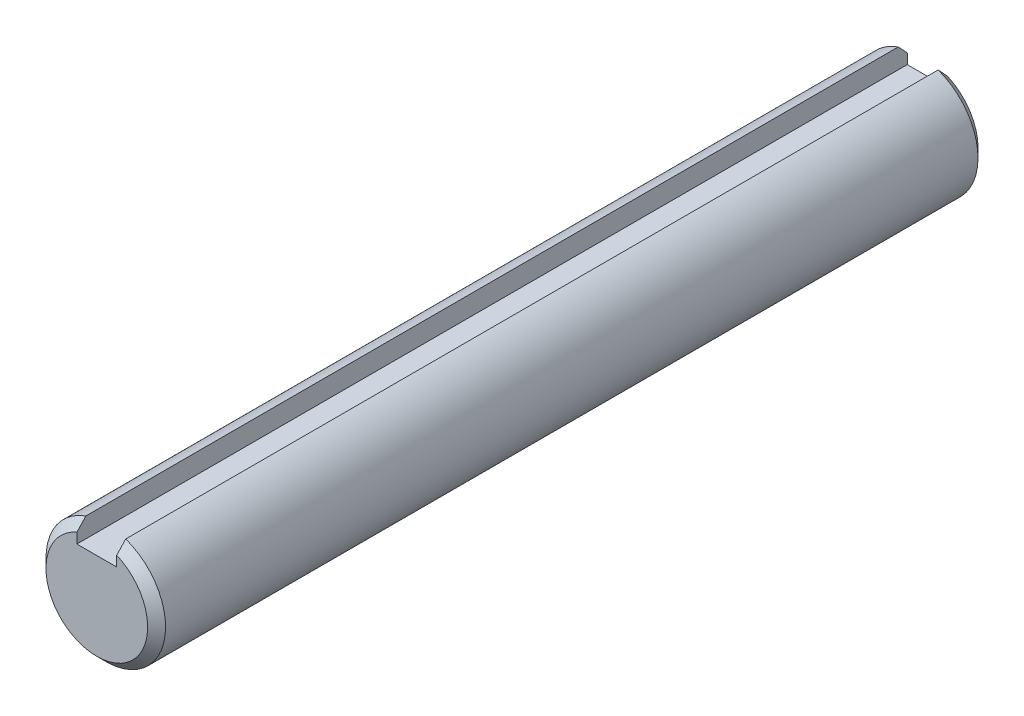
from build123d import *

# Parameters (mm, degrees)
SKETCH1_R           = 9
EXTRUDE1_DEPTH      = 62.5
CHAMFER1_SIZE       = 1.35
SKETCH3_W           = 6
SKETCH3_H           = 3.5
EXTRUDE2_DEPTH      = 63.5
EXTRUDE2_DEPTH_BACK = 63.5


with BuildPart() as part:
    # Sketch1 → Extrude1 (new body, symmetric)
    with BuildSketch(Plane.XY):
        Circle(SKETCH1_R)
    extrude(amount=EXTRUDE1_DEPTH, both=True)

    # Chamfer1
    chamfer1_edges = [part.edges().sort_by_distance(p)[0] for p in [
        (-9, 0, -62.5),
        (-9, 0, 62.5),
    ]]
    chamfer(chamfer1_edges, length=CHAMFER1_SIZE)

    # Sketch3 → Extrude2 (cut, two sides)
    with BuildSketch(Plane.XY) as extrude2_sk:
        with Locations((0, 7.25)):
            Rectangle(SKETCH3_W, SKETCH3_H)
    extrude(amount=EXTRUDE2_DEPTH, mode=Mode.SUBTRACT)
    extrude(extrude2_sk.sketch, amount=-EXTRUDE2_DEPTH_BACK, mode=Mode.SUBTRACT)


solid = part.part
